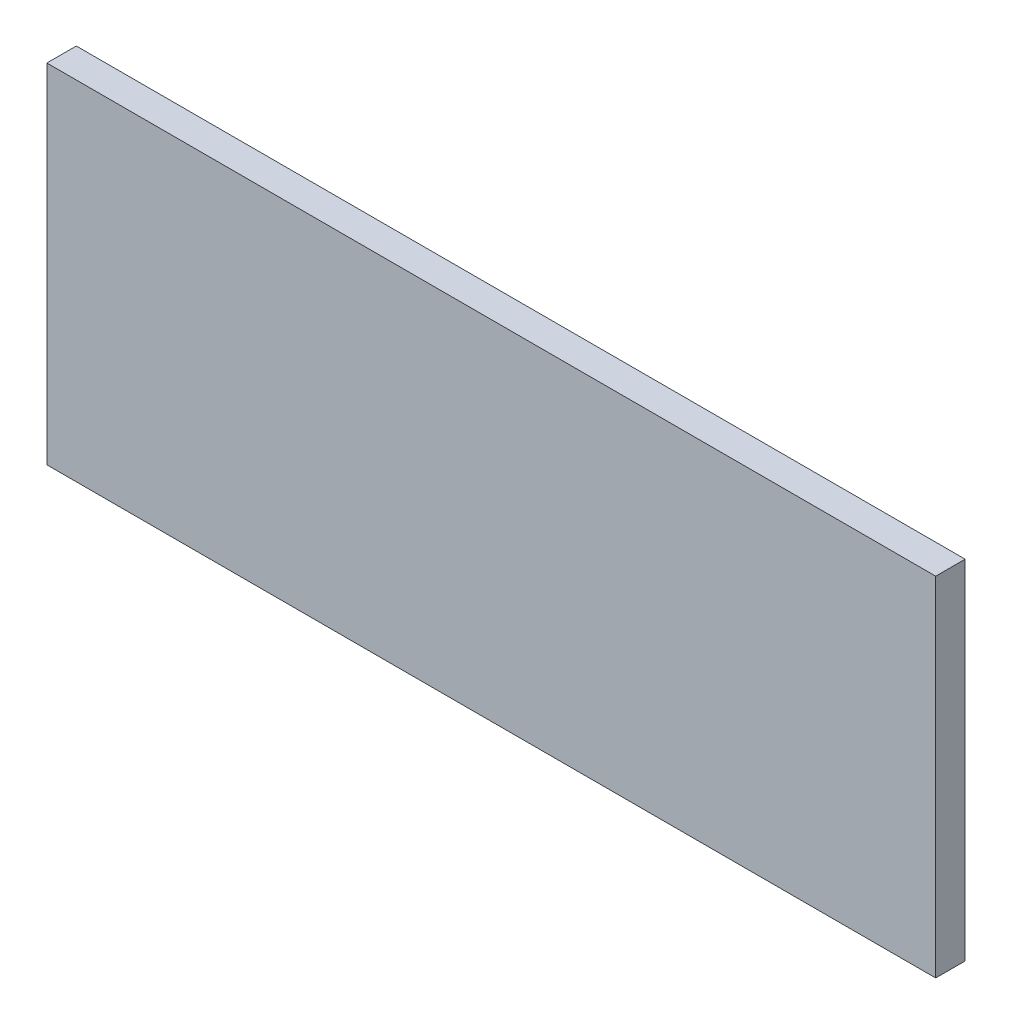
from build123d import *

# Parameters (mm, degrees)
SKETCH1_W           = 23.008
SKETCH1_H           = 9.008
BOSS_EXTRUDE1_DEPTH = 0.762


with BuildPart() as part:
    # Sketch1 → Boss-Extrude1 (new body)
    with BuildSketch(Plane.XY):
        with Locations((3082.138757164, 1134.305694712)):
            Rectangle(SKETCH1_W, SKETCH1_H)
    extrude(amount=BOSS_EXTRUDE1_DEPTH)


solid = part.part
